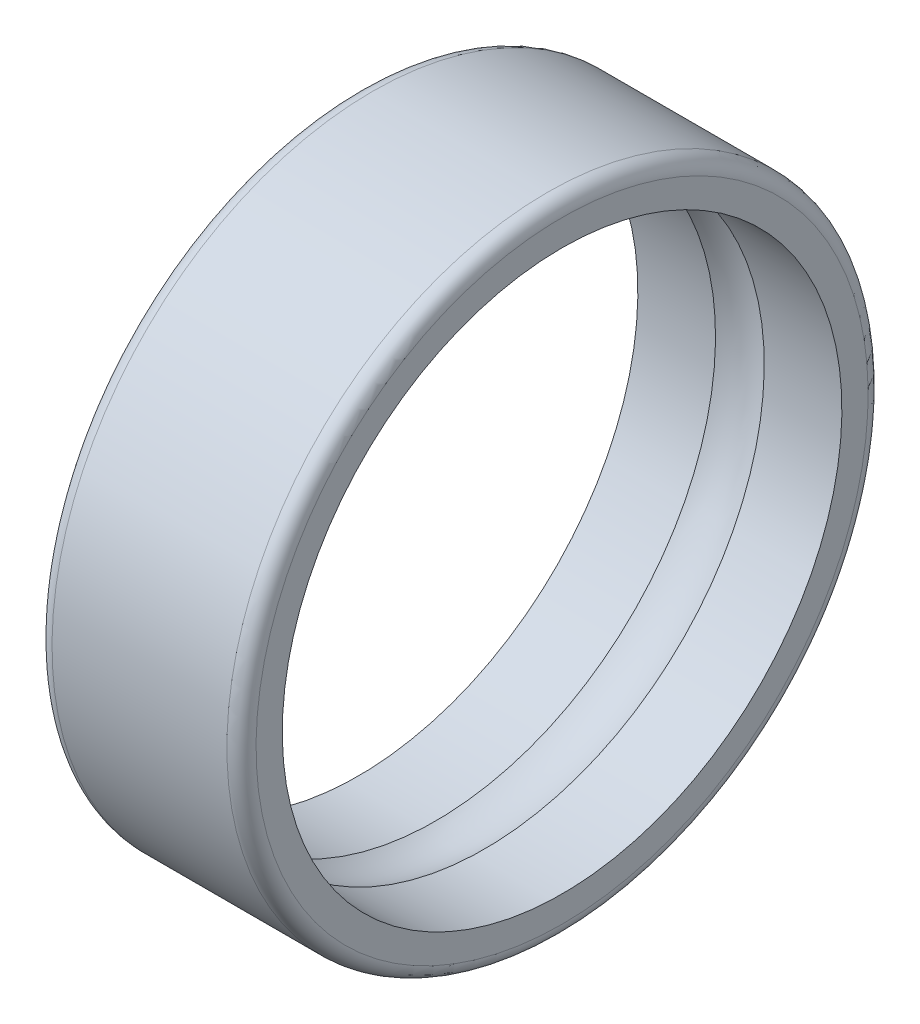
from build123d import *

# Parameters (mm, degrees)
FILLET1_R = 0.5


with BuildPart() as part:
    # Sketch2 → Revolve1 (revolve)
    with BuildSketch(Plane.XY):
        with BuildLine():
            Line((3.5, 9.6), (3.5, 11))
            Line((3.5, 11), (-3.5, 11))
            Line((-3.5, 11), (-3.5, 9.6))
            Line((-3.5, 9.6), (-0.835607713, 9.6))
            ThreePointArc((-0.835607713, 9.6), (0, 9.7845), (0.835607713, 9.6))
            Line((0.835607713, 9.6), (3.5, 9.6))
        make_face()
    revolve(axis=Axis((23.660185957, 0, 0), (-1, 0, 0)))

    # Fillet1
    fillet1_edges = [part.edges().sort_by_distance(p)[0] for p in [
        (-3.5, -11, 0),
        (3.5, -11, 0),
    ]]
    fillet(fillet1_edges, radius=FILLET1_R)


solid = part.part
